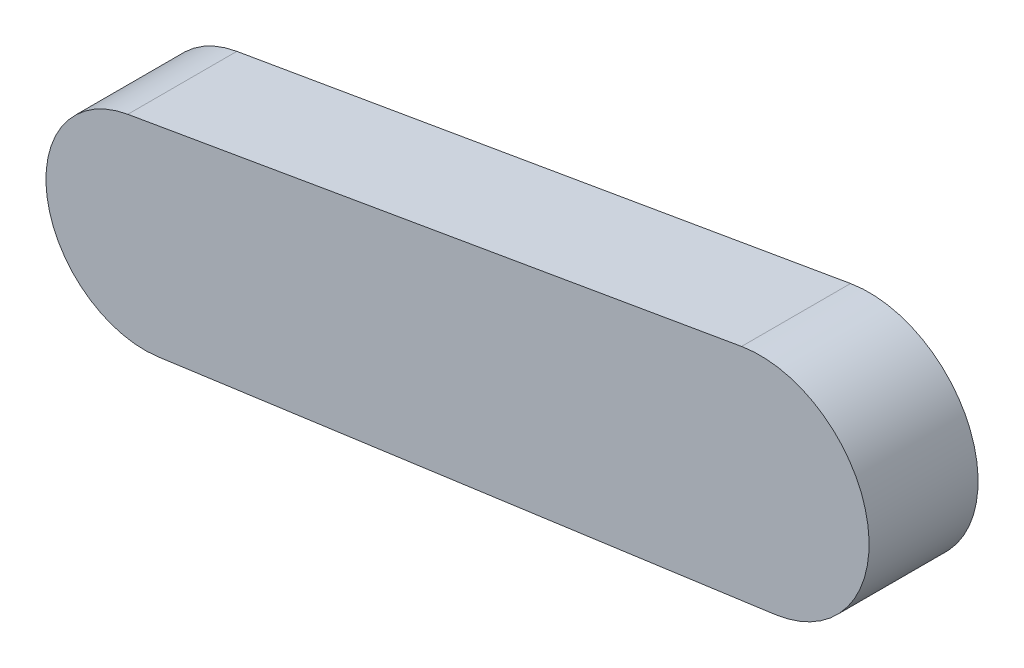
from build123d import *

# Parameters (mm, degrees)
BOSS_EXTRUDE1_DEPTH = 53.34


with BuildPart() as part:
    # Sketch1 → Boss-Extrude1 (new body)
    with BuildSketch(Plane.XY):
        with BuildLine():
            Line((-999.939370706, 508.178787336), (-699.613721868, 559.96428965))
            ThreePointArc((-699.613721868, 559.96428965), (-637.841949448, 515.586391411), (-683.243213202, 454.562830637))
            Line((-683.243213202, 454.562830637), (-985.127958103, 412.815562514))
            ThreePointArc((-985.127958103, 412.815562514), (-1039.427096704, 453.213885424), (-999.939370706, 508.178787336))
        make_face()
    extrude(amount=BOSS_EXTRUDE1_DEPTH)


solid = part.part
